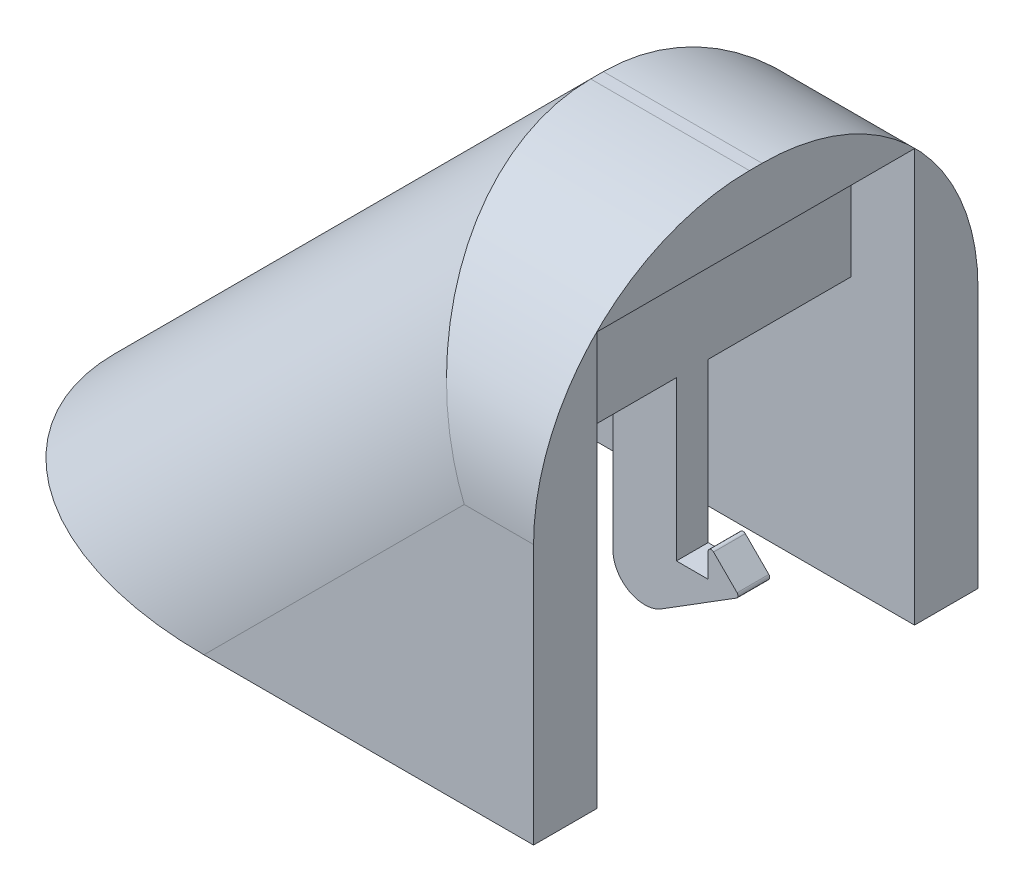
from build123d import *

# Parameters (mm, degrees)
BOSS_EXTRUDE1_DEPTH = 7
SHELL1_T            = -2
BOSS_EXTRUDE2_REACH = 14
SKETCH2_W           = 2
SKETCH2_H           = 10
SKETCH3_W           = 2
SKETCH3_H           = 1
BOSS_EXTRUDE3_DEPTH = 5
SKETCH4_W           = 15.171572875
SKETCH4_H           = 10
CUT_EXTRUDE1_DEPTH  = 5
SKETCH5_W           = 4
SKETCH5_H           = 1
BOSS_EXTRUDE4_DEPTH = 2.5
CUT_EXTRUDE2_REACH  = 9.5
BOSS_EXTRUDE5_START = -1
BOSS_EXTRUDE5_DEPTH = 1
FILLET2_R           = 0.1
FILLET3_R           = 1
FILLET4_R           = 6.8


with BuildPart() as part:
    # Sketch1 → Boss-Extrude1 (new body, symmetric)
    with BuildSketch(Plane.XY):
        Polygon((0, 0), (0, 15), (-5, 15), (-20, 0), align=None)
    extrude(amount=BOSS_EXTRUDE1_DEPTH, both=True)

    # Shell1
    shell1_openings = [part.faces().sort_by_distance(p)[0] for p in [
        (0, 7.5, 0),
    ]]
    offset(amount=SHELL1_T, openings=shell1_openings, kind=Kind.INTERSECTION)

    # Sketch2 → Boss-Extrude2 (add, up to next)
    with BuildSketch(Plane.XY.offset(-5), mode=Mode.PRIVATE) as boss_extrude2_sk1:
        with Locations((-3, 13.501498051)):
            Rectangle(SKETCH2_W, SKETCH2_H)
    boss_extrude2_tool1 = extrude(boss_extrude2_sk1.sketch, amount=BOSS_EXTRUDE2_REACH, mode=Mode.PRIVATE) - part.part
    add(boss_extrude2_tool1.solids().sort_by_distance((-3, 13.501498, -5))[0])

    # Sketch3 → Boss-Extrude3 (add)
    with BuildSketch(Plane.XZ.offset(-8.501498051)):
        with Locations((-3, 0)):
            Rectangle(SKETCH3_W, SKETCH3_H)
    extrude(amount=BOSS_EXTRUDE3_DEPTH)

    # Sketch4 → Cut-Extrude1 (cut)
    with BuildSketch(Plane(origin=(0, 2, 0), x_dir=(1, 0, 0), z_dir=(0, 1, 0))):
        with Locations((-7.585786438, 0)):
            Rectangle(SKETCH4_W, SKETCH4_H)
    extrude(amount=-CUT_EXTRUDE1_DEPTH, mode=Mode.SUBTRACT)

    # Sketch5 → Boss-Extrude4 (add)
    with BuildSketch(Plane(origin=(0, 3.501498051, 0), x_dir=(-1, 0, 0), z_dir=(0, -1, 0))):
        with Locations((2, 0)):
            Rectangle(SKETCH5_W, SKETCH5_H)
    extrude(amount=BOSS_EXTRUDE4_DEPTH)

    # Sketch6 → Cut-Extrude2 (cut, up to next)
    with BuildSketch(Plane.XY.offset(0.5), mode=Mode.PRIVATE) as cut_extrude2_sk1:
        Polygon((0, 3.501498051), (-4, 1.001498051), (0, 1.001498051), align=None)
    cut_extrude2_tool1 = extrude(cut_extrude2_sk1.sketch, amount=-CUT_EXTRUDE2_REACH, mode=Mode.PRIVATE) & part.part
    add(cut_extrude2_tool1.solids().sort_by_distance((-1.333333, 1.834831, 0.5))[0], mode=Mode.SUBTRACT)

    # Sketch7 → Boss-Extrude5 (add)
    with BuildSketch(Plane.XY.offset(0.5).offset(BOSS_EXTRUDE5_START)):
        Polygon((0, 3.501498051), (-1, 3.501498051), (-1, 4.501498051), align=None)
    extrude(amount=BOSS_EXTRUDE5_DEPTH)

    # Fillet2
    fillet2_edges = [part.edges().sort_by_distance(p)[0] for p in [
        (0, 3.501498051, 0),
        (-1, 4.501498051, 0),
    ]]
    fillet(fillet2_edges, radius=FILLET2_R)

    # Fillet3
    fillet3_edges = [part.edges().sort_by_distance(p)[0] for p in [
        (-4, 1.001498051, 0),
    ]]
    fillet(fillet3_edges, radius=FILLET3_R)

    # Fillet4
    fillet4_edges = [part.edges().sort_by_distance(p)[0] for p in [
        (-2.5, 15, 7),
        (-12.5, 7.5, 7),
        (-12.5, 7.5, -7),
        (-2.5, 15, -7),
    ]]
    fillet(fillet4_edges, radius=FILLET4_R)


solid = part.part
